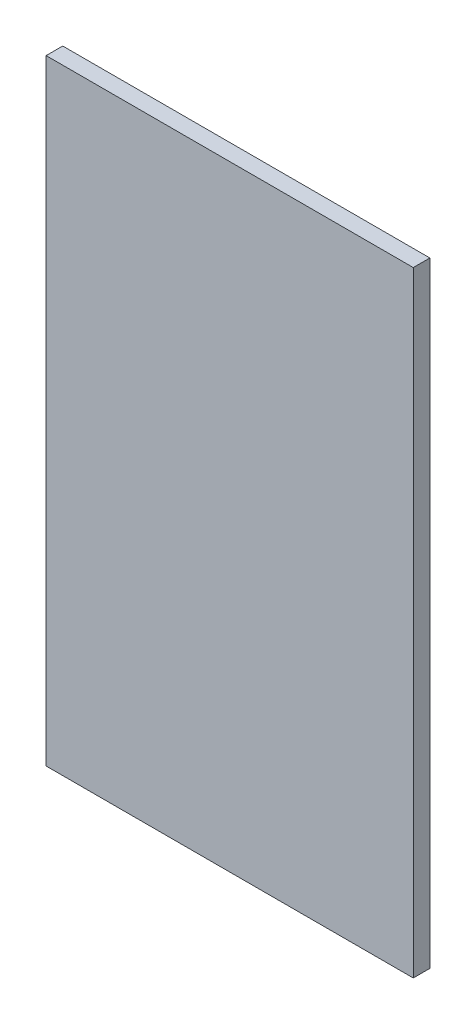
from build123d import *

# Parameters (mm, degrees)
SKETCH1_W           = 398
SKETCH1_H           = 667
BOSS_EXTRUDE1_DEPTH = 18


with BuildPart() as part:
    # Sketch1 → Boss-Extrude1 (new body)
    with BuildSketch(Plane.XY):
        Rectangle(SKETCH1_W, SKETCH1_H)
    extrude(amount=BOSS_EXTRUDE1_DEPTH)


solid = part.part
